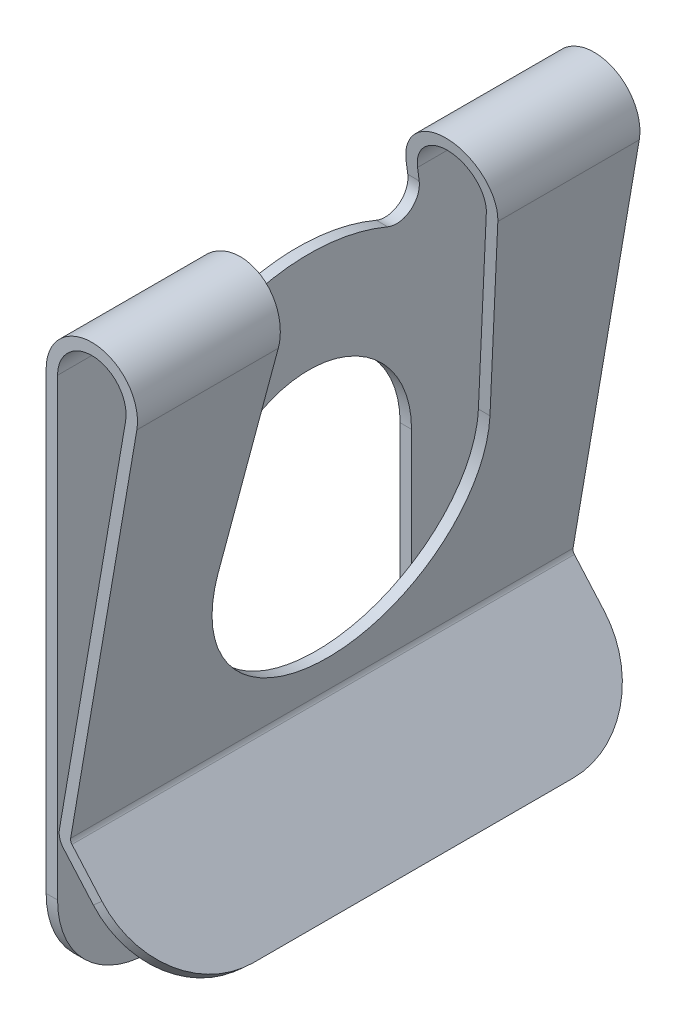
from build123d import *

# Parameters (mm, degrees)
BOSS_EXTRUDE1_DEPTH      = 11
BOSS_EXTRUDE1_DEPTH_BACK = 11
CUT_EXTRUDE1_DEPTH       = 0.5
CUT_EXTRUDE2_DEPTH       = 5
CUT_EXTRUDE3_DEPTH       = 5
CUT_EXTRUDE4_DEPTH       = 0.5
CUT_EXTRUDE5_DEPTH       = 0.5
CUT_EXTRUDE6_DEPTH       = 0.5
CUT_EXTRUDE7_DEPTH       = 0.5
CUT_EXTRUDE8_DEPTH       = 1
CUT_EXTRUDE8_DEPTH_BACK  = 1


with BuildPart() as part:
    # Sketch1 → Boss-Extrude1 (new, two sides: drawn at the far end of the back side and taken through both)
    with BuildSketch(Plane.XY.offset(-BOSS_EXTRUDE1_DEPTH_BACK)):
        with BuildLine():
            Line((0, 9.8), (0, -14.1))
            Line((0, -14.1), (0.5, -14.1))
            Line((0.5, -14.1), (0.5, 9.8))
            ThreePointArc((0.5, 9.8), (2.126963265, 11.294617118), (3.478507106, 9.546984708))
            Line((3.478507106, 9.546984708), (0.580460074, -7.387893417))
            ThreePointArc((0.580460074, -7.387893417), (0.597810426, -7.717762239), (0.75519649, -8.008182798))
            Line((0.75519649, -8.008182798), (4.700431296, -12.518581837))
            Line((4.700431296, -12.518581837), (5.076776054, -12.189394014))
            Line((5.076776054, -12.189394014), (1.131541248, -7.678994975))
            ThreePointArc((1.131541248, -7.678994975), (1.079079227, -7.582188122), (1.073295776, -7.472231848))
            Line((1.073295776, -7.472231848), (3.971342808, 9.462646278))
            ThreePointArc((3.971342808, 9.462646278), (2.169284353, 11.792822824), (0, 9.8))
        make_face()
    extrude(amount=BOSS_EXTRUDE1_DEPTH + BOSS_EXTRUDE1_DEPTH_BACK)

    # Sketch2 → Cut-Extrude1 (cut)
    with BuildSketch(Plane(origin=(0, 0, 0), x_dir=(0, 0, -1), z_dir=(1, 0, 0))):
        with BuildLine():
            Line((-4.5, 0), (-4.5, -14.1))
            Line((-4.5, -14.1), (4.5, -14.1))
            Line((4.5, -14.1), (4.5, 0))
            ThreePointArc((4.5, 0), (0, 4.5), (-4.5, 0))
        make_face()
    extrude(amount=CUT_EXTRUDE1_DEPTH, mode=Mode.SUBTRACT)

    # Sketch3 → Cut-Extrude2 (cut)
    with BuildSketch(Plane(origin=(0.5, 0, 0), x_dir=(0, 0, -1), z_dir=(1, 0, 0))):
        with BuildLine():
            Line((5.948789681, 0.782241223), (4.5, 11.8))
            Line((4.5, 11.8), (-4.5, 11.8))
            Line((-4.5, 11.8), (-5.948789681, 0.782241223))
            ThreePointArc((-5.948789681, 0.782241223), (0, -6), (5.948789681, 0.782241223))
        make_face()
    extrude(amount=CUT_EXTRUDE2_DEPTH, mode=Mode.SUBTRACT)

    # Sketch4 → Cut-Extrude3 (cut)
    with BuildSketch(Plane(origin=(0.5, 0, 0), x_dir=(0, 0, -1), z_dir=(1, 0, 0))):
        with BuildLine():
            Line((4.834801398, 9.253901634), (4.5, 11.8))
            Line((4.5, 11.8), (-4.5, 11.8))
            Line((-4.5, 11.8), (-4.834801398, 9.253901634))
            ThreePointArc((-4.834801398, 9.253901634), (-4.449655576, 8.328306669), (-3.455120629, 8.20195961))
            ThreePointArc((-3.455120629, 8.20195961), (1.1e-08, 8.9), (3.455120648, 8.201959602))
            ThreePointArc((3.455120648, 8.201959602), (4.449655585, 8.328306676), (4.834801398, 9.253901634))
        make_face()
    extrude(amount=-CUT_EXTRUDE3_DEPTH, mode=Mode.SUBTRACT)

    # Sketch5 → Cut-Extrude4 (cut)
    with BuildSketch(Plane(origin=(0, 0, 0), x_dir=(0, 0, -1), z_dir=(1, 0, 0))):
        with BuildLine():
            Line((-11, -14.1), (-7, -14.1))
            ThreePointArc((-7, -14.1), (-9.828427125, -12.928427125), (-11, -10.1))
            Line((-11, -10.1), (-11, -14.1))
        make_face()
    extrude(amount=CUT_EXTRUDE4_DEPTH, mode=Mode.SUBTRACT)

    # Sketch6 → Cut-Extrude5 (cut)
    with BuildSketch(Plane(origin=(0, 0, 0), x_dir=(0, 0, -1), z_dir=(1, 0, 0))):
        with BuildLine():
            Line((7, -14.1), (11, -14.1))
            Line((11, -14.1), (11, -10.1))
            ThreePointArc((11, -10.1), (9.828427125, -12.928427125), (7, -14.1))
        make_face()
    extrude(amount=CUT_EXTRUDE5_DEPTH, mode=Mode.SUBTRACT)

    # Sketch7 → Cut-Extrude6 (cut)
    with BuildSketch(Plane(origin=(0, 0, 0), x_dir=(0, 0, -1), z_dir=(1, 0, 0))):
        with BuildLine():
            Line((4.5, -14.1), (5.5, -14.1))
            ThreePointArc((5.5, -14.1), (4.792893219, -13.807106781), (4.5, -13.1))
            Line((4.5, -13.1), (4.5, -14.1))
        make_face()
    extrude(amount=CUT_EXTRUDE6_DEPTH, mode=Mode.SUBTRACT)

    # Sketch8 → Cut-Extrude7 (cut)
    with BuildSketch(Plane(origin=(0, 0, 0), x_dir=(0, 0, -1), z_dir=(1, 0, 0))):
        with BuildLine():
            Line((-5.5, -14.1), (-4.5, -14.1))
            Line((-4.5, -14.1), (-4.5, -13.1))
            ThreePointArc((-4.5, -13.1), (-4.792893219, -13.807106781), (-5.5, -14.1))
        make_face()
    extrude(amount=CUT_EXTRUDE7_DEPTH, mode=Mode.SUBTRACT)

    # Sketch9 → Cut-Extrude8 (cut, two sides: drawn at the far end of the back side and taken through both)
    with BuildSketch(Plane(origin=(-3.164279663, -2.76778754, 0), x_dir=(0, 0, -1), z_dir=(0.7526895169963331, 0.6583756458161457, 0)).offset(-CUT_EXTRUDE8_DEPTH_BACK)):
        with BuildLine():
            Line((-11, -8.516878218), (-15, -8.516878218))
            Line((-15, -8.516878218), (-15, -16.516878218))
            Line((-15, -16.516878218), (15, -16.516878218))
            Line((15, -16.516878218), (15, -8.516878218))
            Line((15, -8.516878218), (11, -8.516878218))
            ThreePointArc((11, -8.516878218), (9.828427125, -11.345305343), (7, -12.516878218))
            Line((7, -12.516878218), (-7, -12.516878218))
            ThreePointArc((-7, -12.516878218), (-9.828427125, -11.345305343), (-11, -8.516878218))
        make_face()
    extrude(amount=CUT_EXTRUDE8_DEPTH + CUT_EXTRUDE8_DEPTH_BACK, mode=Mode.SUBTRACT)


solid = part.part
